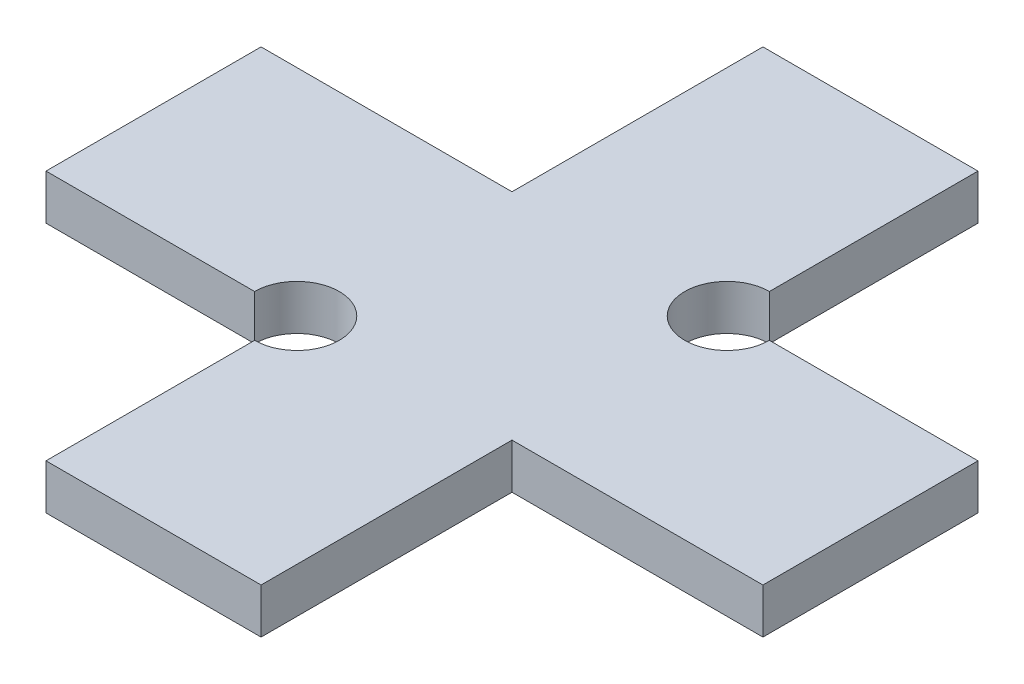
from build123d import *

# Parameters (mm, degrees)
BOSS_EXTRUDE1_DEPTH = 1.6


with BuildPart() as part:
    # Sketch1 → Boss-Extrude1 (new body)
    with BuildSketch(Plane(origin=(0, 0, 0), x_dir=(1, 0, 0), z_dir=(0, 1, 0))):
        with BuildLine():
            Line((-12.7, -3.81), (-5.31, -3.81))
            ThreePointArc((-5.31, -3.81), (-4.870660172, -2.749339828), (-3.81, -2.31))
            Line((-3.81, -2.31), (-3.81, 3.81))
            Line((-3.81, 3.81), (-12.7, 3.81))
            Line((-12.7, 3.81), (-12.7, -3.81))
        make_face()
        with BuildLine():
            Line((-2.31, -3.81), (3.81, -3.81))
            Line((3.81, -3.81), (3.81, 2.31))
            ThreePointArc((3.81, 2.31), (2.749339828, 2.749339828), (2.31, 3.81))
            Line((2.31, 3.81), (-3.81, 3.81))
            Line((-3.81, 3.81), (-3.81, -2.31))
            ThreePointArc((-3.81, -2.31), (-2.749339828, -2.749339828), (-2.31, -3.81))
        make_face()
        with BuildLine():
            Line((-3.81, -12.7), (3.81, -12.7))
            Line((3.81, -12.7), (3.81, -3.81))
            Line((3.81, -3.81), (-2.31, -3.81))
            ThreePointArc((-2.31, -3.81), (-2.749339828, -4.870660172), (-3.81, -5.31))
            Line((-3.81, -5.31), (-3.81, -12.7))
        make_face()
        with BuildLine():
            Line((3.81, 2.31), (3.81, -3.81))
            Line((3.81, -3.81), (12.7, -3.81))
            Line((12.7, -3.81), (12.7, 3.81))
            Line((12.7, 3.81), (5.31, 3.81))
            ThreePointArc((5.31, 3.81), (4.870660172, 2.749339828), (3.81, 2.31))
        make_face()
        with BuildLine():
            Line((-3.81, 3.81), (2.31, 3.81))
            ThreePointArc((2.31, 3.81), (2.749339828, 4.870660172), (3.81, 5.31))
            Line((3.81, 5.31), (3.81, 12.7))
            Line((3.81, 12.7), (-3.81, 12.7))
            Line((-3.81, 12.7), (-3.81, 3.81))
        make_face()
    extrude(amount=BOSS_EXTRUDE1_DEPTH)


solid = part.part
